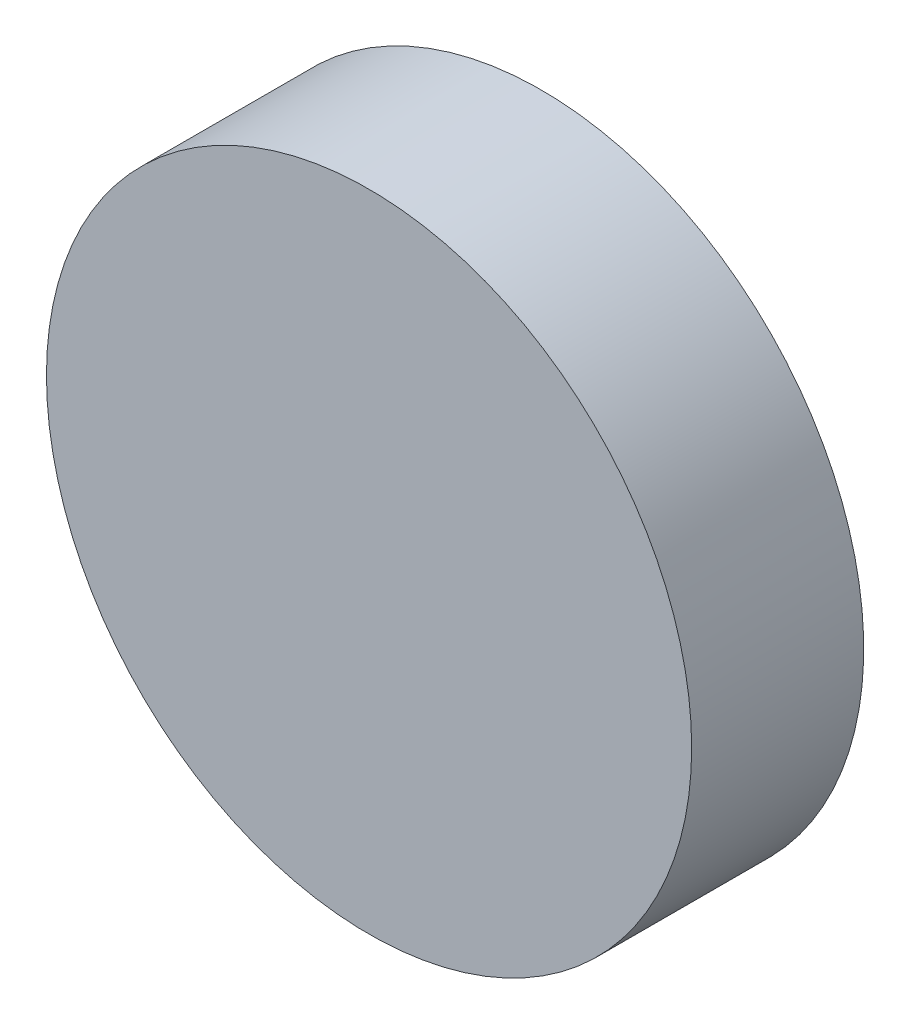
from build123d import *

# Parameters (mm, degrees)
CROQUIS1_R              = 15
SALIENTE_EXTRUIR3_DEPTH = 2
CROQUIS3_R              = 7.5
SALIENTE_EXTRUIR4_DEPTH = 4
CROQUIS4_R              = 15
CORTAR_EXTRUIR1_DEPTH   = 2


with BuildPart() as part:
    # Croquis1 → Saliente-Extruir3 (new body)
    with BuildSketch(Plane.XY):
        Circle(CROQUIS1_R)
    extrude(amount=SALIENTE_EXTRUIR3_DEPTH)

    # Croquis3 → Saliente-Extruir4 (add)
    with BuildSketch(Plane.XY.offset(2)):
        Circle(CROQUIS3_R)
    extrude(amount=SALIENTE_EXTRUIR4_DEPTH)

    # Croquis4 → Cortar-Extruir1 (cut)
    with BuildSketch(Plane(origin=(0, 0, 0), x_dir=(-1, 0, 0), z_dir=(0, 0, -1))):
        Circle(CROQUIS4_R)
    extrude(amount=-CORTAR_EXTRUIR1_DEPTH, mode=Mode.SUBTRACT)


solid = part.part
